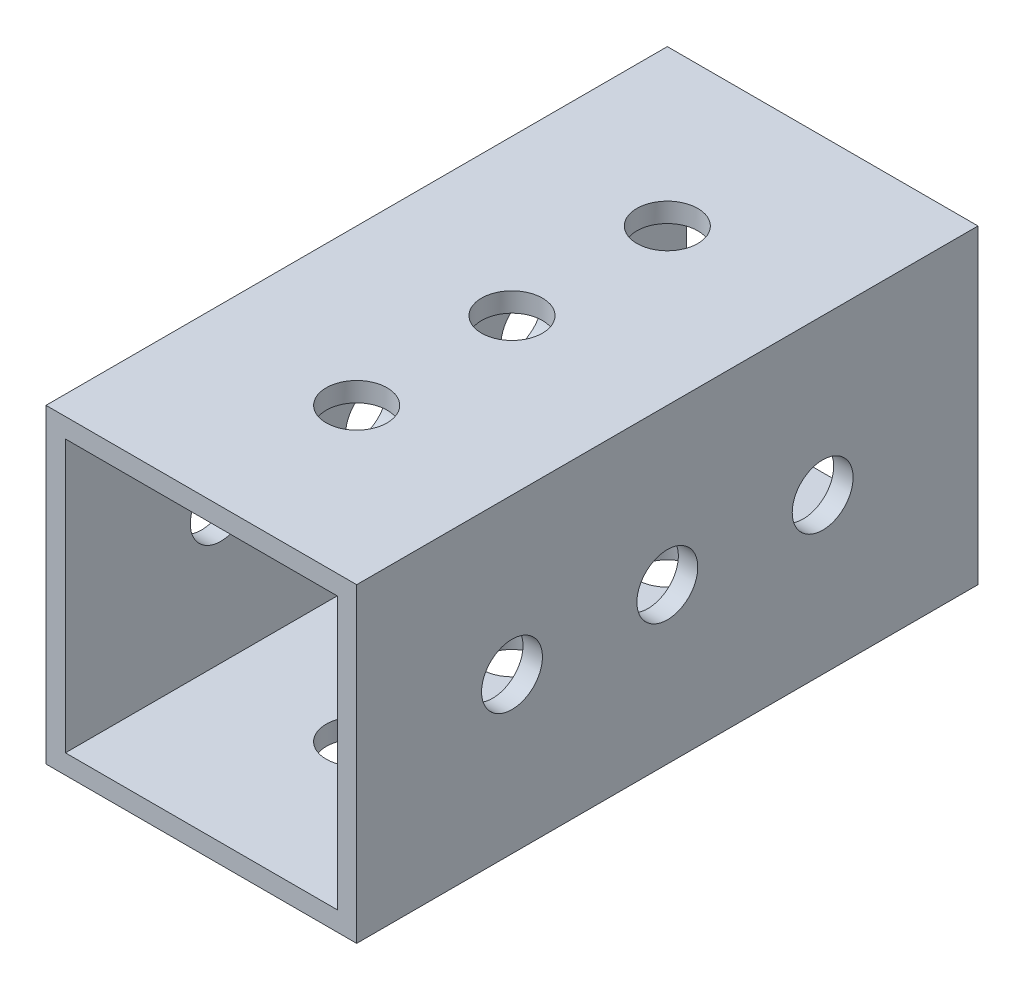
from build123d import *

# Parameters (mm, degrees)
SKETCH1_W           = 25.4
SKETCH1_H           = 25.4
SKETCH1_W_2         = 22.225
SKETCH1_H_2         = 22.225
BOSS_EXTRUDE1_DEPTH = 50.8
SKETCH2_R           = 2.4892
CUT_EXTRUDE1_DEPTH  = 26.4
SKETCH3_R           = 2.4892
CUT_EXTRUDE2_DEPTH  = 26.4


with BuildPart() as part:
    # Sketch1 → Boss-Extrude1 (new body)
    with BuildSketch(Plane.XY):
        with Locations((12.7, 12.7)):
            Rectangle(SKETCH1_W, SKETCH1_H)
        with Locations((12.7, 12.7)):
            Rectangle(SKETCH1_W_2, SKETCH1_H_2, mode=Mode.SUBTRACT)
    extrude(amount=BOSS_EXTRUDE1_DEPTH)

    # Sketch2 → Cut-Extrude1 (cut, through all)
    with BuildSketch(Plane(origin=(0, 25.4, 0), x_dir=(1, 0, 0), z_dir=(0, 1, 0))):
        with Locations((12.7, -12.7)):
            Circle(SKETCH2_R)
        with Locations((12.7, -25.4)):
            Circle(SKETCH2_R)
        with Locations((12.7, -38.1)):
            Circle(SKETCH2_R)
    extrude(amount=-CUT_EXTRUDE1_DEPTH, mode=Mode.SUBTRACT)

    # Sketch3 → Cut-Extrude2 (cut, through all)
    with BuildSketch(Plane.ZY):
        with Locations((12.7, 12.7)):
            Circle(SKETCH3_R)
        with Locations((25.4, 12.7)):
            Circle(SKETCH3_R)
        with Locations((38.1, 12.7)):
            Circle(SKETCH3_R)
    extrude(amount=-CUT_EXTRUDE2_DEPTH, mode=Mode.SUBTRACT)


solid = part.part
